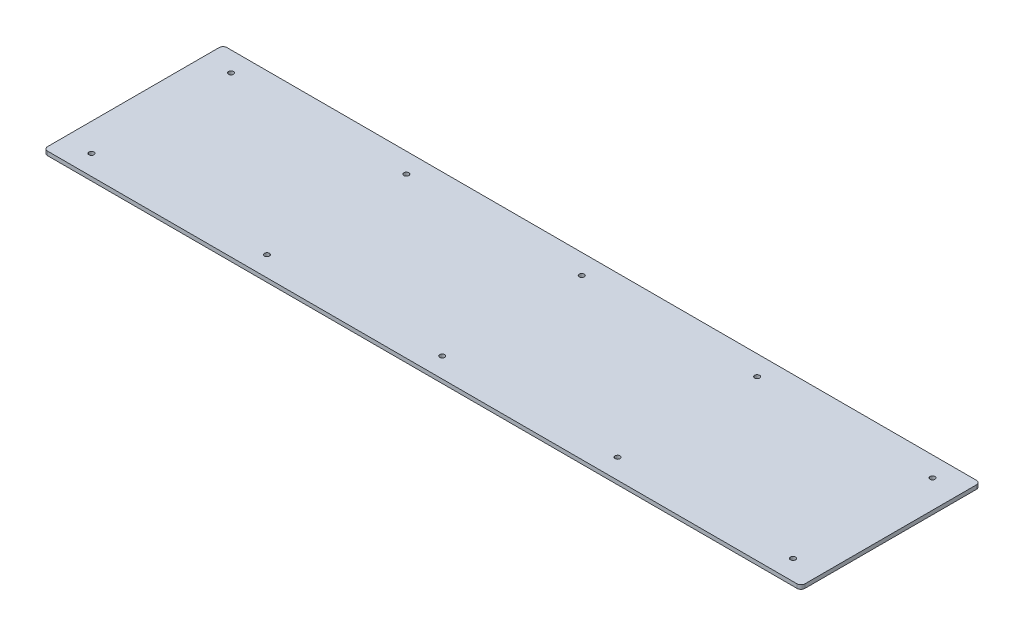
from build123d import *

# Parameters (mm, degrees)
SKETCH1_W                      = 1206.5
SKETCH1_H                      = 285.75
BOSS_EXTRUDE1_DEPTH            = 6.35
F_5_16_0_3125_DIAMETER_HOLE1_D = 7.9375
LPATTERN1_COUNT                = 5
LPATTERN1_PITCH                = 279.4
LPATTERN1_COUNT_DIR2           = 2
LPATTERN1_PITCH_DIR2           = 222.25
FILLET1_R                      = 6.35


with BuildPart() as part:
    # Sketch1 → Boss-Extrude1 (new body)
    with BuildSketch(Plane(origin=(0, 0, 0), x_dir=(1, 0, 0), z_dir=(0, 1, 0))):
        with Locations((603.25, 142.875)):
            Rectangle(SKETCH1_W, SKETCH1_H)
    extrude(amount=BOSS_EXTRUDE1_DEPTH)

    # 5/16 (0.3125) Diameter Hole1 (through all)
    with Locations(Plane(origin=(0, 6.35, 0), x_dir=(1, 0, 0), z_dir=(0, 1, 0))):
        with Locations((44.45, 31.75)):
            f_5_16_0_3125_diameter_hole1 = Hole(F_5_16_0_3125_DIAMETER_HOLE1_D / 2)

    # LPattern1: 5_16 _0.3125_ Diameter Hole1 5 × 2
    with Locations(*[(i * LPATTERN1_PITCH, 0, -j * LPATTERN1_PITCH_DIR2) for i in range(LPATTERN1_COUNT) for j in range(LPATTERN1_COUNT_DIR2) if (i, j) != (0, 0)]):
        add(f_5_16_0_3125_diameter_hole1, mode=Mode.SUBTRACT)

    # Fillet1
    fillet1_edges = [part.edges().sort_by_distance(p)[0] for p in [
        (0, 3.175, -285.75),
        (1206.5, 3.175, -285.75),
        (1206.5, 3.175, 0),
        (0, 3.175, 0),
    ]]
    fillet(fillet1_edges, radius=FILLET1_R)


solid = part.part
